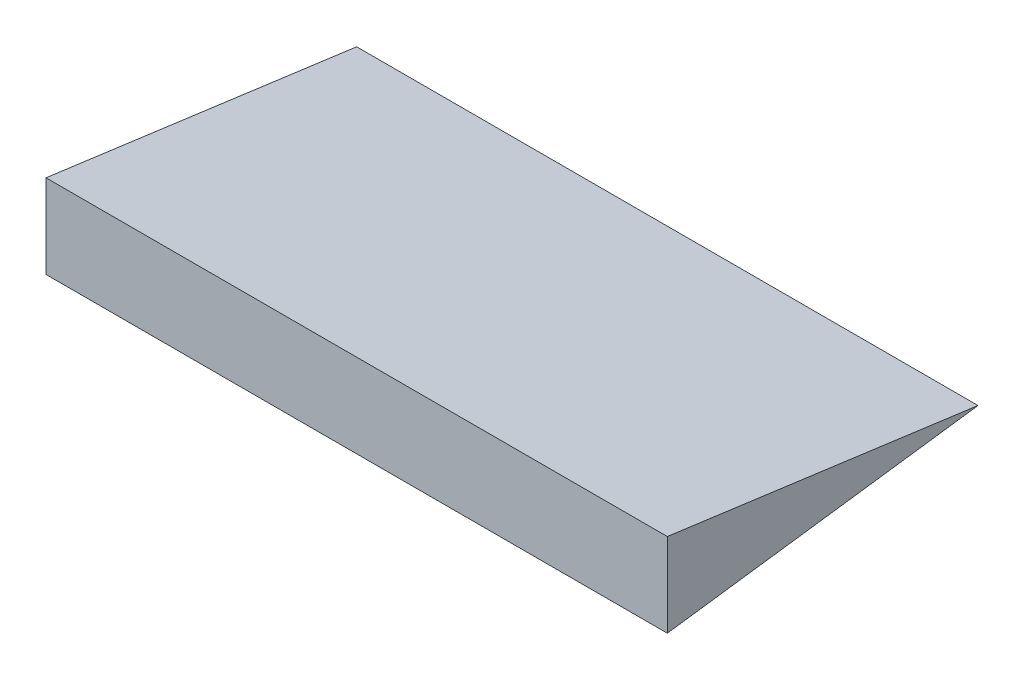
from build123d import *

# Parameters (mm, degrees)
BOSS_EXTRUDE1_DEPTH = 50


with BuildPart() as part:
    # aileron_root → Boss-Extrude1 (new, symmetric)
    with BuildSketch(Plane(origin=(0, 0, 0), x_dir=(0, 0, -1), z_dir=(1, 0, 0))):
        Polygon((-50, -6.738836743), (-50, 6.738836743), (0, 0), align=None)
    extrude(amount=BOSS_EXTRUDE1_DEPTH, both=True)


solid = part.part
